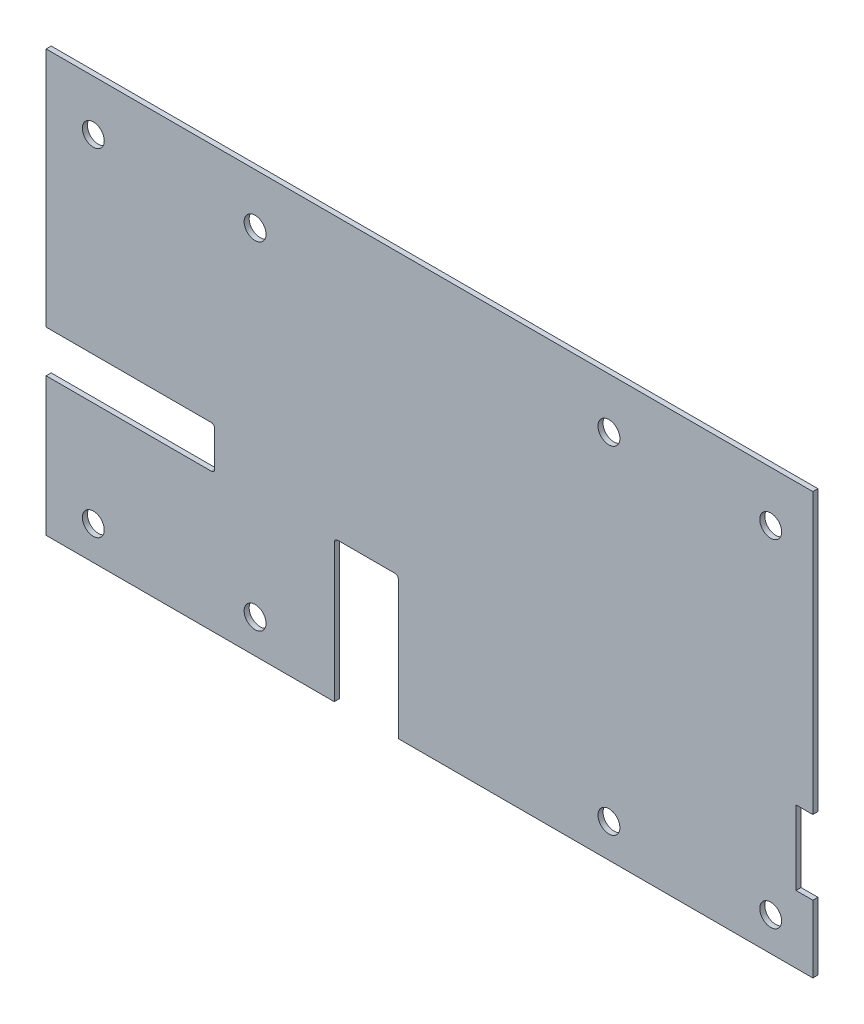
from build123d import *

# Parameters (mm, degrees)
ESQUISSE1_W             = 455
ESQUISSE1_H             = 250
ESQUISSE1_R             = 6.5
BOSS_EXTRU_1_DEPTH      = 3
ESQUISSE4_W             = 100
ESQUISSE4_H             = 25
ESQUISSE4_W_2           = 38
ESQUISSE4_H_2           = 84
ESQUISSE4_W_3           = 10
ESQUISSE4_H_3           = 44
ENL_V_MAT_EXTRU_3_DEPTH = 10
CONG_1_R                = 2


with BuildPart() as part:
    # Esquisse1 → Boss.-Extru.1 (new body)
    with BuildSketch(Plane.XY):
        Rectangle(ESQUISSE1_W, ESQUISSE1_H)
        with Locations((106.5, 95)):
            Circle(ESQUISSE1_R, mode=Mode.SUBTRACT)
        with Locations((202.5, 95)):
            Circle(ESQUISSE1_R, mode=Mode.SUBTRACT)
        with Locations((106.5, -105)):
            Circle(ESQUISSE1_R, mode=Mode.SUBTRACT)
        with Locations((202.5, -105)):
            Circle(ESQUISSE1_R, mode=Mode.SUBTRACT)
        with Locations((-103.5, -105)):
            Circle(ESQUISSE1_R, mode=Mode.SUBTRACT)
        with Locations((-103.5, 95)):
            Circle(ESQUISSE1_R, mode=Mode.SUBTRACT)
        with Locations((-199.5, 95)):
            Circle(ESQUISSE1_R, mode=Mode.SUBTRACT)
        with Locations((-199.5, -105)):
            Circle(ESQUISSE1_R, mode=Mode.SUBTRACT)
    extrude(amount=BOSS_EXTRU_1_DEPTH)

    # Esquisse4 → Enlèv. mat.-Extru.3 (cut)
    with BuildSketch(Plane.XY.offset(3)):
        with Locations((-177.5, -30.5)):
            Rectangle(ESQUISSE4_W, ESQUISSE4_H)
        with Locations((-37.5, -83)):
            Rectangle(ESQUISSE4_W_2, ESQUISSE4_H_2)
        with Locations((222.5, -63)):
            Rectangle(ESQUISSE4_W_3, ESQUISSE4_H_3)
    extrude(amount=-ENL_V_MAT_EXTRU_3_DEPTH, mode=Mode.SUBTRACT)

    # Congé1
    cong_1_edges = [part.edges().sort_by_distance(p)[0] for p in [
        (-127.5, -18, 1.5),
        (-127.5, -43, 1.5),
        (-56.5, -41, 1.5),
        (-18.5, -41, 1.5),
    ]]
    fillet(cong_1_edges, radius=CONG_1_R)


solid = part.part
